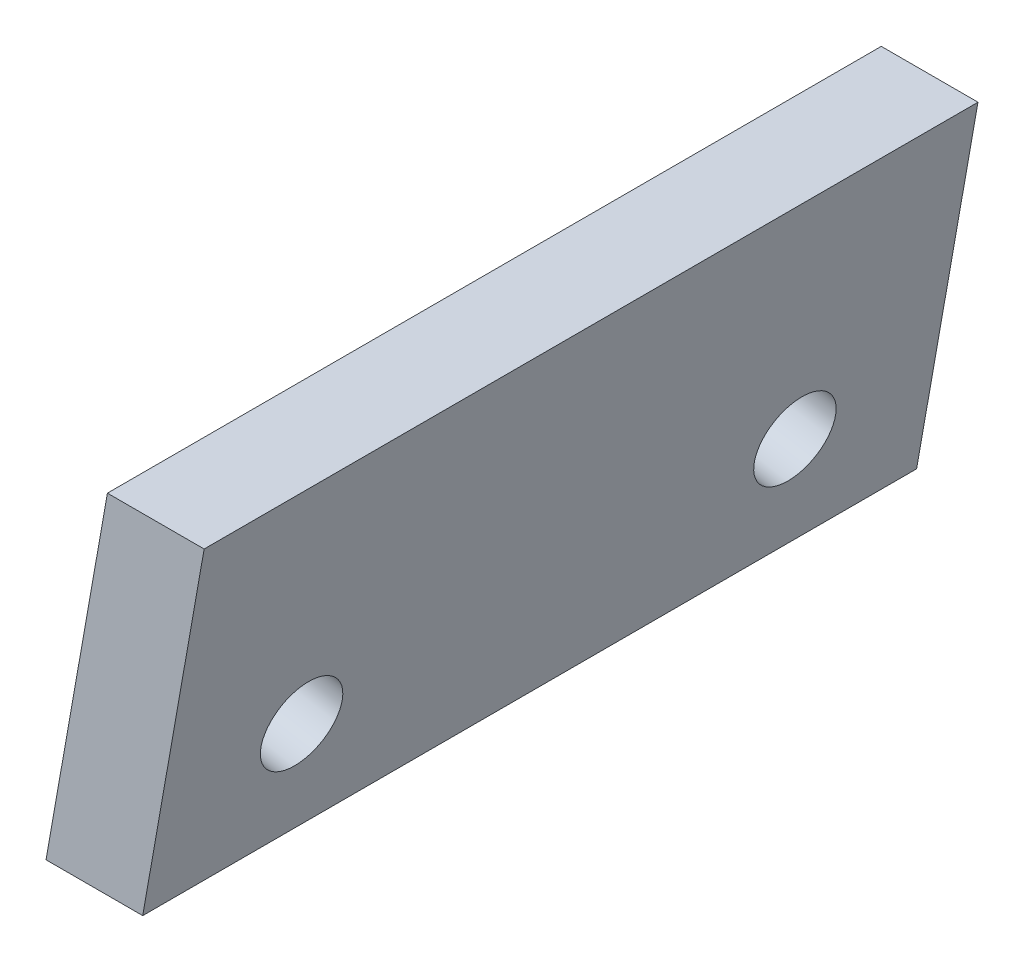
from build123d import *

# Parameters (mm, degrees)
BOSS_EXTRUDE2_DEPTH = 20
SKETCH4_R           = 1.05
CUT_EXTRUDE1_DEPTH  = 5.024852982


with BuildPart() as part:
    # Sketch2 → Boss-Extrude2 (new body)
    with BuildSketch(Plane.XY):
        Polygon((0, 0), (2.5, 0), (4.086942826, 9), (1.586942826, 9), align=None)
    extrude(amount=BOSS_EXTRUDE2_DEPTH)

    # Sketch4 → Cut-Extrude1 (cut, through all)
    with BuildSketch(Plane(origin=(0, 0, 0), x_dir=(0, 0, 1), z_dir=(-0.984807753, 0.173648178, 0))):
        with Locations((3.625, 3.2)):
            Circle(SKETCH4_R)
        with Locations((16.375, 3.2)):
            Circle(SKETCH4_R)
    extrude(amount=-CUT_EXTRUDE1_DEPTH, mode=Mode.SUBTRACT)


solid = part.part
